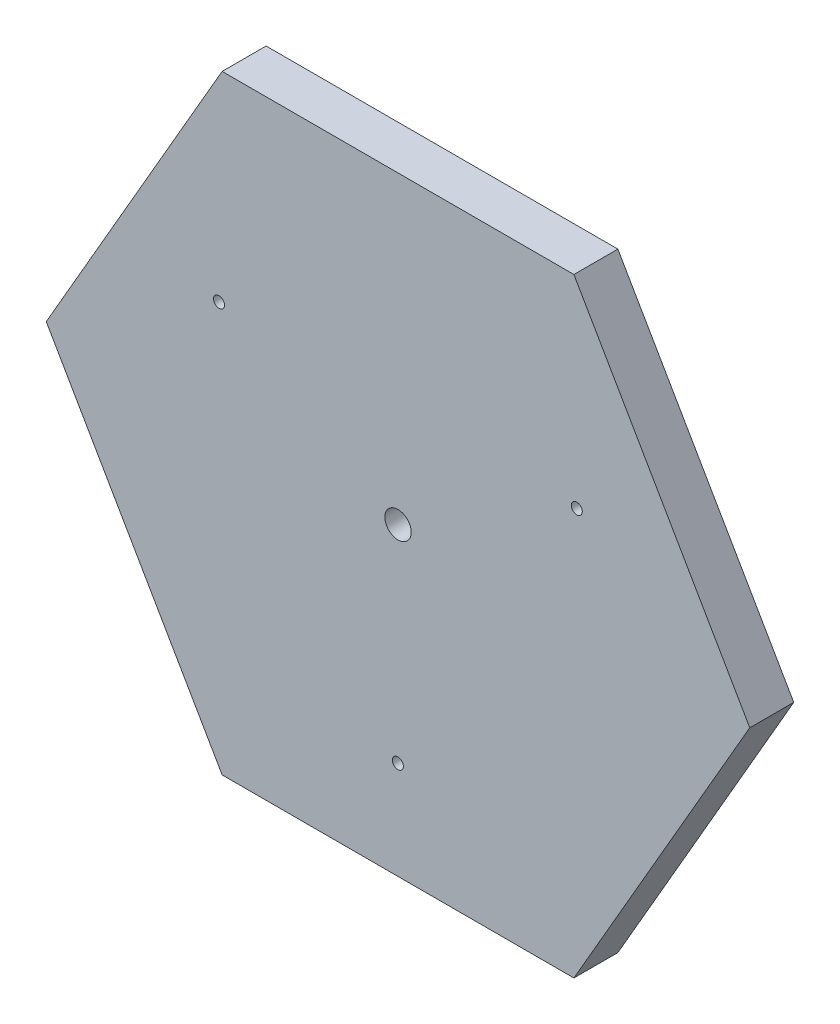
from build123d import *

# Parameters (mm, degrees)
ESBO_O1_R                = 1.25
ESBO_O1_R_2              = 3
RESSALTO_EXTRUS_O1_DEPTH = 10


with BuildPart() as part:
    # Esboço1 → Ressalto-extrusão1 (new body)
    with BuildSketch(Plane.XY):
        Polygon((24.538271299, 125.53639711), (-15.461728701, 56.254364807), (24.538271299, -13.027667496), (104.538271299, -13.027667496), (144.538271299, 56.254364807), (104.538271299, 125.53639711), align=None)
        with Locations((23.829756558, 79.75978664)):
            Circle(ESBO_O1_R, mode=Mode.SUBTRACT)
        with Locations((64.5, 9.254436228)):
            Circle(ESBO_O1_R, mode=Mode.SUBTRACT)
        with Locations((105.194995267, 79.766124623)):
            Circle(ESBO_O1_R, mode=Mode.SUBTRACT)
        with Locations((64.538271299, 56.254364807)):
            Circle(ESBO_O1_R_2, mode=Mode.SUBTRACT)
    extrude(amount=RESSALTO_EXTRUS_O1_DEPTH)


solid = part.part
